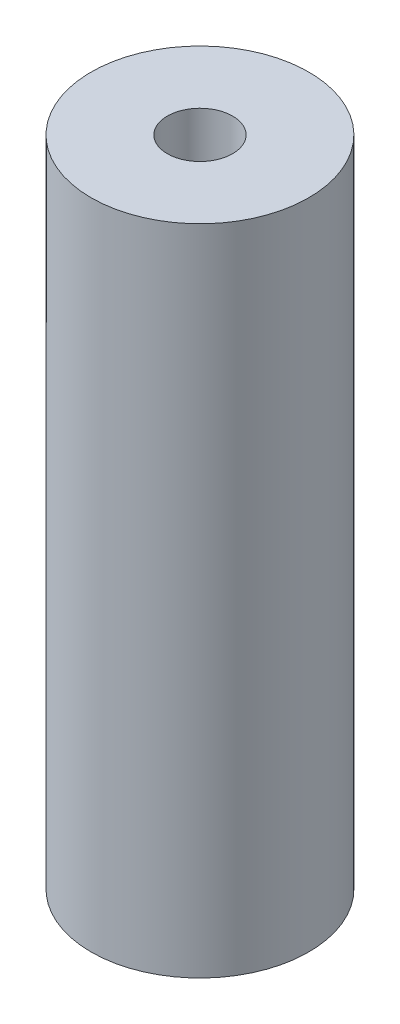
from build123d import *

# Parameters (mm, degrees)
CROQUIS1_R              = 5
SALIENTE_EXTRUIR1_DEPTH = 30
CROQUIS2_R              = 1.5
CORTAR_EXTRUIR1_DEPTH   = 5
CROQUIS4_R              = 1.5
CORTAR_EXTRUIR2_DEPTH   = 5


with BuildPart() as part:
    # Croquis1 → Saliente-Extruir1 (new body)
    with BuildSketch(Plane(origin=(0, 0, 0), x_dir=(1, 0, 0), z_dir=(0, 1, 0))):
        Circle(CROQUIS1_R)
    extrude(amount=SALIENTE_EXTRUIR1_DEPTH)

    # Croquis2 → Cortar-Extruir1 (cut)
    with BuildSketch(Plane(origin=(0, 30, 0), x_dir=(1, 0, 0), z_dir=(0, 1, 0))):
        Circle(CROQUIS2_R)
    extrude(amount=-CORTAR_EXTRUIR1_DEPTH, mode=Mode.SUBTRACT)

    # Croquis4 → Cortar-Extruir2 (cut)
    with BuildSketch(Plane.XZ):
        Circle(CROQUIS4_R)
    extrude(amount=-CORTAR_EXTRUIR2_DEPTH, mode=Mode.SUBTRACT)


solid = part.part
